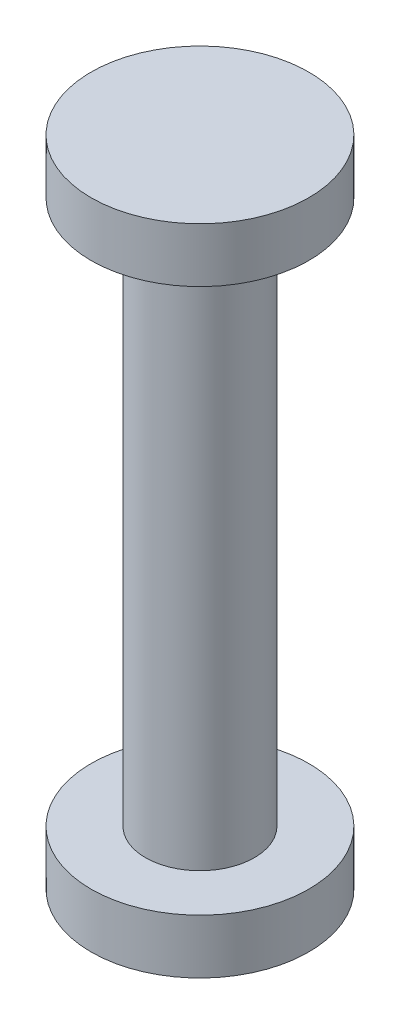
from build123d import *

# Parameters (mm, degrees)
SKETCH1_R           = 5
BOSS_EXTRUDE1_DEPTH = 50
SKETCH2_R           = 10
BOSS_EXTRUDE2_DEPTH = 5


with BuildPart() as part:
    # Sketch1 → Boss-Extrude1 (new body)
    with BuildSketch(Plane(origin=(0, 0, 0), x_dir=(1, 0, 0), z_dir=(0, 1, 0))):
        Circle(SKETCH1_R)
    extrude(amount=BOSS_EXTRUDE1_DEPTH)

    # Sketch2 → Boss-Extrude2 (add)
    with BuildSketch(Plane(origin=(0, 50, 0), x_dir=(1, 0, 0), z_dir=(0, 1, 0))):
        Circle(SKETCH2_R)
    boss_extrude2 = extrude(amount=BOSS_EXTRUDE2_DEPTH)

    # Mirror1: Boss-Extrude2 across plane
    add(boss_extrude2.mirror(Plane(origin=(0, 25, 0), x_dir=(0, 0, 1), z_dir=(0, -1, 0))))


solid = part.part
